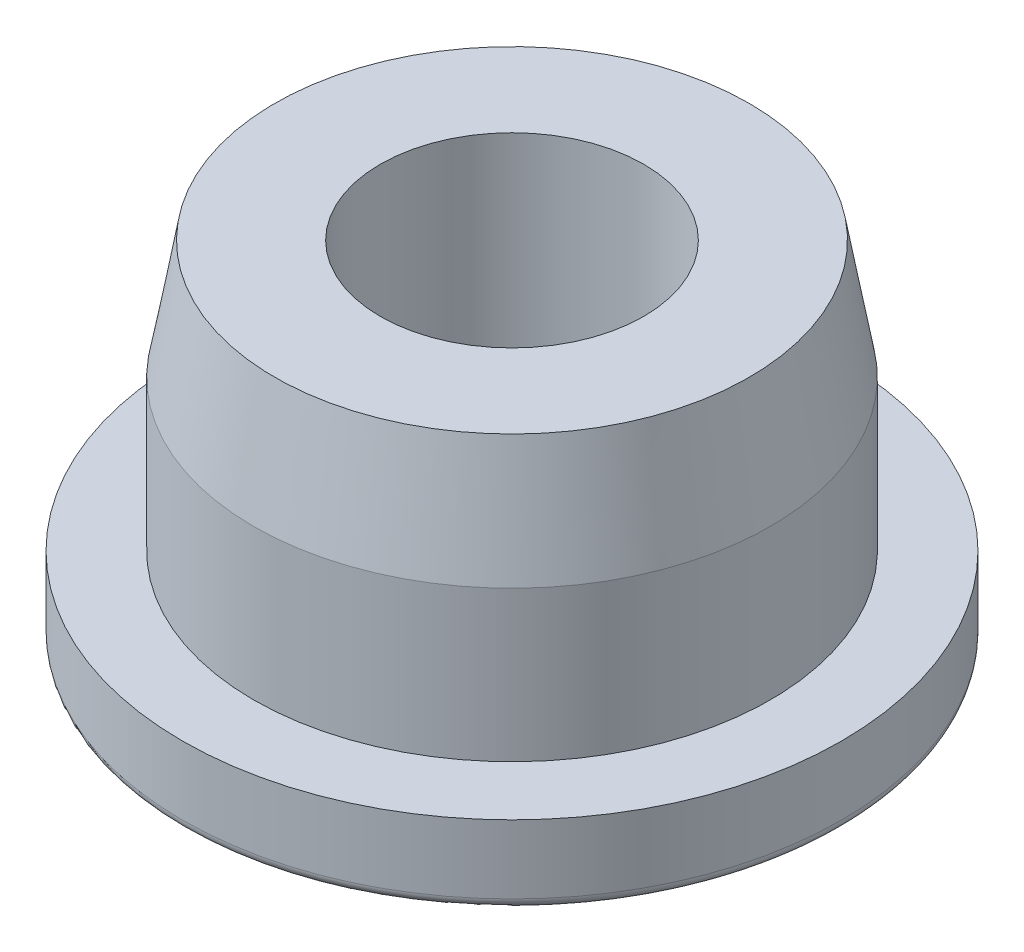
from build123d import *

# Parameters (mm, degrees)
FILLET1_R = 0.4


with BuildPart() as part:
    # Sketch1 → Revolve1 (revolve)
    with BuildSketch(Plane(origin=(0, 0, 0), x_dir=(0, 0, -1), z_dir=(1, 0, 0))):
        Polygon((0, 0), (-12.5, 0), (-12.5, 3), (-9.8, 3), (-9.8, 8.7), (-9, 13.2), (-5, 13.2), (-5, 2.8), (0, 2.8), align=None)
    revolve(axis=Axis((0, 0, 0), (0, 1, 0)))

    # Fillet1
    fillet1_edges = [part.edges().sort_by_distance(p)[0] for p in [
        (0, 0, -12.5),
    ]]
    fillet(fillet1_edges, radius=FILLET1_R)


solid = part.part
